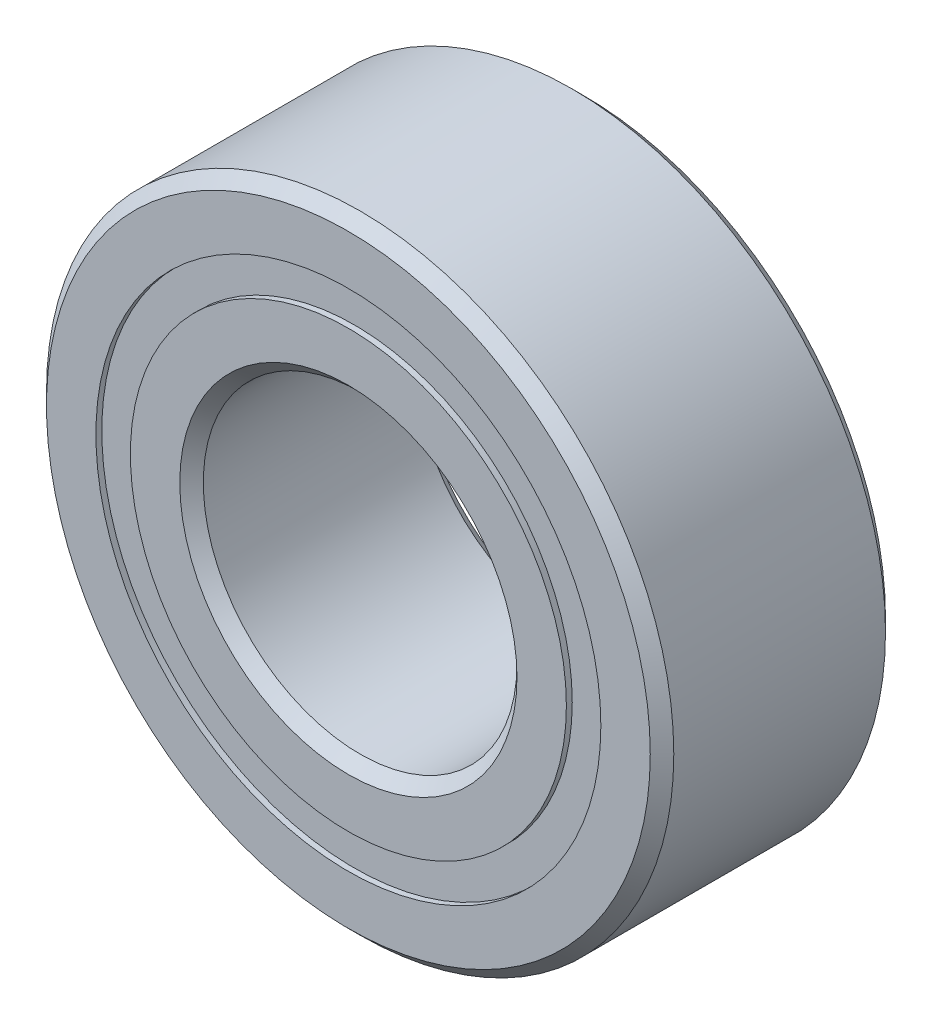
from build123d import *


with BuildPart() as part:
    # Sketch1 → Revolve1 (revolve)
    with BuildSketch(Plane(origin=(0, 0, 0), x_dir=(1, 0, 0), z_dir=(0, 1, 0))):
        Polygon((6.35, -2.143125), (6.35, 2.143125), (6.111875, 2.38125), (5.111401099, 2.38125), (5.111401099, 2.2621875), (4.413598901, 2.2621875), (4.413598901, 2.38125), (3.413125, 2.38125), (3.175, 2.143125), (3.175, -2.143125), (3.413125, -2.38125), (4.413598901, -2.38125), (4.413598901, -2.2621875), (5.111401099, -2.2621875), (5.111401099, -2.38125), (6.111875, -2.38125), align=None)
    revolve(axis=Axis((0, 0, -2.38125), (0, 0, 1)))


solid = part.part
